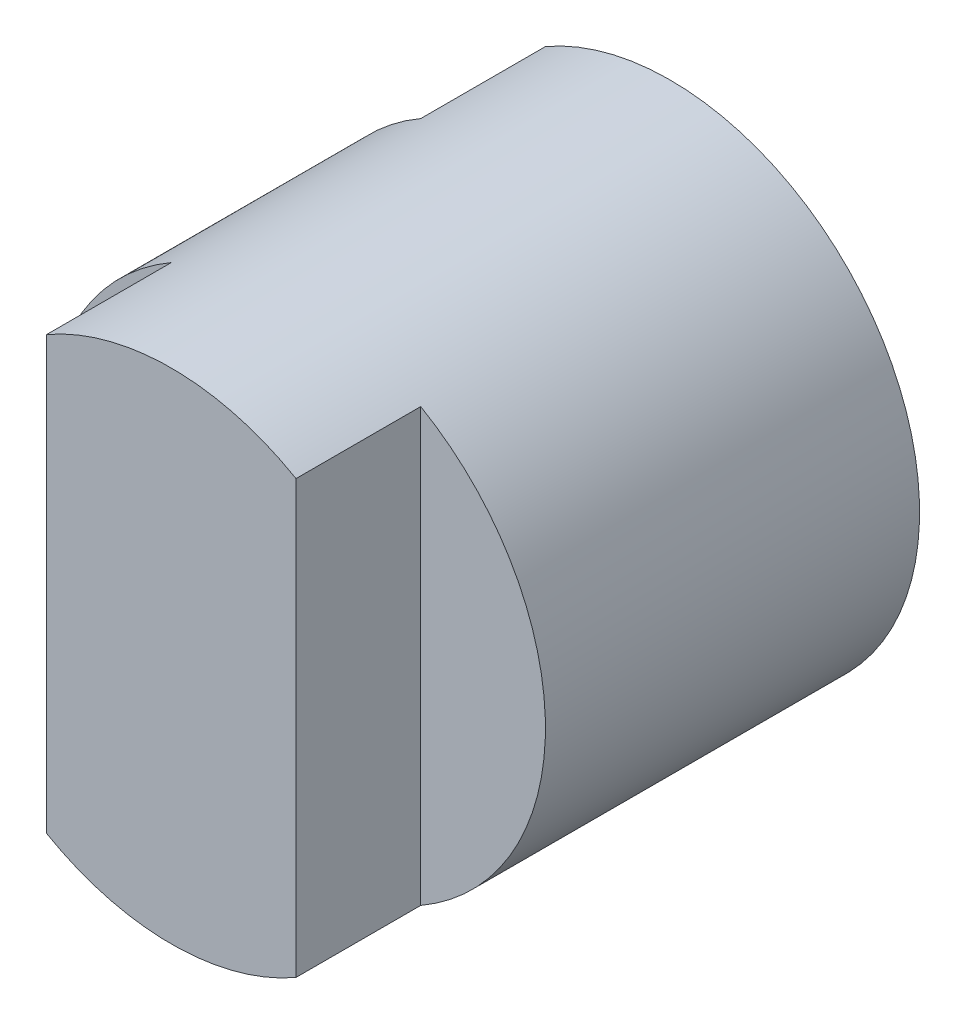
from build123d import *

# Parameters (mm, degrees)
SKETCH1_R           = 2
BOSS_EXTRUDE1_DEPTH = 4
CUT_EXTRUDE1_DEPTH  = 5


with BuildPart() as part:
    # Sketch1 → Boss-Extrude1 (new body)
    with BuildSketch(Plane.XY):
        Circle(SKETCH1_R)
    extrude(amount=BOSS_EXTRUDE1_DEPTH)

    # Sketch2 → Cut-Extrude1 (cut, symmetric)
    with BuildSketch(Plane(origin=(0, 0, 0), x_dir=(1, 0, 0), z_dir=(0, 1, 0))):
        Polygon((2, -3), (1, -3), (1, -4.221507546), (-1, -4.26455627), (-1, -3), (-2.31386892, -3), (-2.31386892, -1), (-1, -1), (-1, 0.234035397), (-2.586760402, 0.199881392), (-2.489753088, -4.306979917), (2, -4.619024092), (2.554571986, -4.221507546), align=None)
    extrude(amount=CUT_EXTRUDE1_DEPTH, both=True, mode=Mode.SUBTRACT)


solid = part.part
